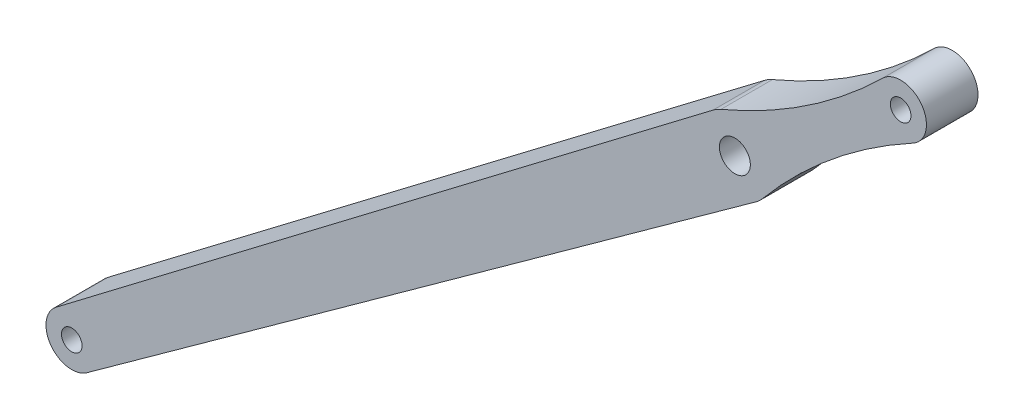
from build123d import *

# Parameters (mm, degrees)
BOSS_EXTRUDE1_DEPTH      = 5
BOSS_EXTRUDE1_DEPTH_BACK = 5
SKETCH1_R                = 2
SKETCH1_R_2              = 3


with BuildPart() as part:
    # Sketch1 → Boss-Extrude1 (new, two sides: drawn at the far end of the back side and taken through both)
    with BuildSketch(Plane.XY.offset(-BOSS_EXTRUDE1_DEPTH_BACK)):
        with BuildLine():
            Line((-228.038090057, 37.726797985), (-98.274394802, 131.307690232))
            ThreePointArc((-98.274394802, 131.307690232), (-97.595390257, 131.865353314), (-96.991595947, 132.503685294))
            ThreePointArc((-96.991595947, 132.503685294), (-83.549961909, 145.833090362), (-67.837220551, 156.390567529))
            ThreePointArc((-67.837220551, 156.390567529), (-66.201860471, 163.76115756), (-73.728811684, 164.348529198))
            ThreePointArc((-73.728811684, 164.348529198), (-88.41310273, 152.401891111), (-105.085651055, 143.436585904))
            ThreePointArc((-105.085651055, 143.436585904), (-105.872432299, 143.045420264), (-106.604012177, 142.558772375))
            Line((-106.604012177, 142.558772375), (-233.987816753, 45.76328523))
            ThreePointArc((-233.987816753, 45.76328523), (-234.98127902, 38.807134518), (-228.038090057, 37.726797985))
        make_face()
        with Locations((-230.962721435, 41.782230305)):
            Circle(SKETCH1_R, mode=Mode.SUBTRACT)
        with Locations((-102.368878731, 136.98529548)):
            Circle(SKETCH1_R_2, mode=Mode.SUBTRACT)
        with Locations((-70.220418055, 160.786061774)):
            Circle(SKETCH1_R, mode=Mode.SUBTRACT)
    extrude(amount=BOSS_EXTRUDE1_DEPTH + BOSS_EXTRUDE1_DEPTH_BACK)


solid = part.part
